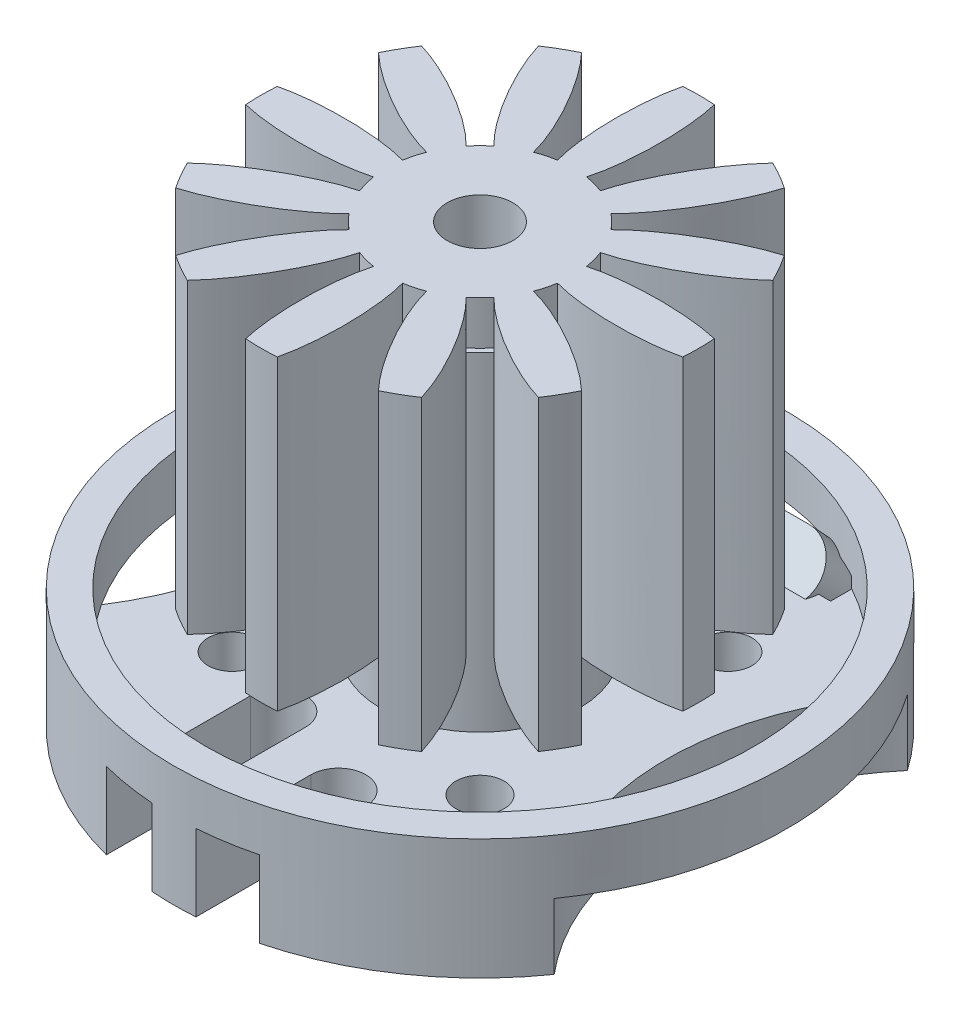
from build123d import *

# Parameters (mm, degrees)
SKETCH1_R                 = 14
BASE_DEPTH                = 5.5
SKETCH2_R                 = 12.5
BASECUT_DEPTH             = 2.5
SKETCH5_R                 = 4.5
OUTERSHAFT_DEPTH          = 15
SKETCH6_R                 = 12.5
LIGHTWEIGHT1_DEPTH        = 3
INDUCTORS_DEPTH           = 14
SKETCH7_W                 = 12
SKETCH7_H                 = 8
LIGHWEIGTH2_DEPTH         = 3.5
SKETCH8_R                 = 3.75
LIGHTWEIGHTFORSHAFT_DEPTH = 0.5
SKETCH9_R                 = 1.5
HOLEFORSHAFT_DEPTH        = 20.5000001
F_2_0_SCREWHOLES_D        = 2.2
F_2_0_SCREWHOLES_DEPTH    = 4
F_2_0_SCREWHOLES_TIP      = 0.660946681
CABLEOUT_DEPTH            = 5
CABLEOUT_TAPER            = 2
SKETCH13_R                = 1
BOSS_EXTRUDE2_DEPTH       = 2


with BuildPart() as part:
    # Sketch1 → Base (new body)
    with BuildSketch(Plane(origin=(0, 0, 0), x_dir=(1, 0, 0), z_dir=(0, 1, 0))):
        Circle(SKETCH1_R)
    extrude(amount=BASE_DEPTH)

    # Sketch2 → BaseCut (cut)
    with BuildSketch(Plane(origin=(0, 5.5, 0), x_dir=(1, 0, 0), z_dir=(0, 1, 0))):
        Circle(SKETCH2_R)
    extrude(amount=-BASECUT_DEPTH, mode=Mode.SUBTRACT)

    # Sketch5 → OuterShaft (add)
    with BuildSketch(Plane(origin=(0, 3, 0), x_dir=(1, 0, 0), z_dir=(0, 1, 0))):
        Circle(SKETCH5_R)
    extrude(amount=OUTERSHAFT_DEPTH)

    # Sketch6 → LightWeight1 (cut)
    with BuildSketch(Plane(origin=(0, 0, 0), x_dir=(-1, 0, 0), z_dir=(0, -1, 0))):
        with Locations((-21, 0)):
            Circle(SKETCH6_R)
        with Locations((21, 0)):
            Circle(SKETCH6_R)
    extrude(amount=-LIGHTWEIGHT1_DEPTH, mode=Mode.SUBTRACT)

    # Sketch4 → Inductors (add)
    with BuildSketch(Plane(origin=(0, 6, 0), x_dir=(1, 0, 0), z_dir=(0, 1, 0))):
        with BuildLine():
            ThreePointArc((-2.671623645, 3.305287748), (-3.00520382, 3.00520382), (-3.305287748, 2.671623645))
            add(Edge.make_bspline(
                [(-3.305287748, 2.671623645), (-5.30672078, 4.732784268), (-8.277571772, 5.610864957)],
                knots=[0.722217358, 0.722217358, 0.722217358, 2.33726322, 2.33726322, 2.33726322], degree=2, weights=[1, 0.691290425, 1]))
            ThreePointArc((-8.277571772, 5.610864957), (-8.660254038, 5), (-8.997937476, 4.363154957))
            add(Edge.make_bspline(
                [(-8.997937476, 4.363154957), (-6.752071797, 2.229362872), (-3.96633782, 1.526651334)],
                knots=[3.945922087, 3.945922087, 3.945922087, 5.560967949, 5.560967949, 5.560967949], degree=2, weights=[1, 0.691290425, 1]))
            ThreePointArc((-3.96633782, 1.526651334), (-4.105184762, 1.099980942), (-4.198274979, 0.661050072))
            add(Edge.make_bspline(
                [(-4.198274979, 0.661050072), (-6.96214714, 1.445351017), (-9.974019914, 0.720365704)],
                knots=[3.863810012, 3.863810012, 3.863810012, 5.478855873, 5.478855873, 5.478855873], degree=2, weights=[1, 0.691290425, 1]))
            ThreePointArc((-9.974019914, 0.720365704), (-10, 0), (-9.974019914, -0.720365704))
            add(Edge.make_bspline(
                [(-9.974019914, -0.720365704), (-6.96214714, -1.445351017), (-4.198274979, -0.661050072)],
                knots=[0.804329434, 0.804329434, 0.804329434, 2.419375295, 2.419375295, 2.419375295], degree=2, weights=[1, 0.691290425, 1]))
            ThreePointArc((-4.198274979, -0.661050072), (-4.105184762, -1.099980942), (-3.96633782, -1.526651334))
            add(Edge.make_bspline(
                [(-3.96633782, -1.526651334), (-6.752071797, -2.229362872), (-8.997937476, -4.363154957)],
                knots=[3.863810012, 3.863810012, 3.863810012, 5.478855873, 5.478855873, 5.478855873], degree=2, weights=[1, 0.691290425, 1]))
            ThreePointArc((-8.997937476, -4.363154957), (-8.660254038, -5), (-8.277571772, -5.610864957))
            add(Edge.make_bspline(
                [(-8.277571772, -5.610864957), (-5.30672078, -4.732784268), (-3.305287748, -2.671623645)],
                knots=[3.945922087, 3.945922087, 3.945922087, 5.560967949, 5.560967949, 5.560967949], degree=2, weights=[1, 0.691290425, 1]))
            ThreePointArc((-3.305287748, -2.671623645), (-3.00520382, -3.00520382), (-2.671623645, -3.305287748))
            add(Edge.make_bspline(
                [(-2.671623645, -3.305287748), (-4.732784268, -5.30672078), (-5.610864957, -8.277571772)],
                knots=[3.863810012, 3.863810012, 3.863810012, 5.478855873, 5.478855873, 5.478855873], degree=2, weights=[1, 0.691290425, 1]))
            ThreePointArc((-5.610864957, -8.277571772), (-5, -8.660254038), (-4.363154957, -8.997937476))
            add(Edge.make_bspline(
                [(-4.363154957, -8.997937476), (-2.229362872, -6.752071797), (-1.526651334, -3.96633782)],
                knots=[0.804329434, 0.804329434, 0.804329434, 2.419375295, 2.419375295, 2.419375295], degree=2, weights=[1, 0.691290425, 1]))
            ThreePointArc((-1.526651334, -3.96633782), (-1.099980942, -4.105184762), (-0.661050072, -4.198274979))
            add(Edge.make_bspline(
                [(-0.661050072, -4.198274979), (-1.445351017, -6.96214714), (-0.720365704, -9.974019914)],
                knots=[3.863810012, 3.863810012, 3.863810012, 5.478855873, 5.478855873, 5.478855873], degree=2, weights=[1, 0.691290425, 1]))
            ThreePointArc((-0.720365704, -9.974019914), (0, -10), (0.720365704, -9.974019914))
            add(Edge.make_bspline(
                [(0.720365704, -9.974019914), (1.445351017, -6.96214714), (0.661050072, -4.198274979)],
                knots=[0.804329434, 0.804329434, 0.804329434, 2.419375295, 2.419375295, 2.419375295], degree=2, weights=[1, 0.691290425, 1]))
            ThreePointArc((0.661050072, -4.198274979), (1.099980942, -4.105184762), (1.526651334, -3.96633782))
            add(Edge.make_bspline(
                [(1.526651334, -3.96633782), (2.229362872, -6.752071797), (4.363154957, -8.997937476)],
                knots=[0.722217358, 0.722217358, 0.722217358, 2.33726322, 2.33726322, 2.33726322], degree=2, weights=[1, 0.691290425, 1]))
            ThreePointArc((4.363154957, -8.997937476), (5, -8.660254038), (5.610864957, -8.277571772))
            add(Edge.make_bspline(
                [(5.610864957, -8.277571772), (4.732784268, -5.30672078), (2.671623645, -3.305287748)],
                knots=[0.804329434, 0.804329434, 0.804329434, 2.419375295, 2.419375295, 2.419375295], degree=2, weights=[1, 0.691290425, 1]))
            ThreePointArc((2.671623645, -3.305287748), (3.00520382, -3.00520382), (3.305287748, -2.671623645))
            add(Edge.make_bspline(
                [(3.305287748, -2.671623645), (5.30672078, -4.732784268), (8.277571772, -5.610864957)],
                knots=[3.863810012, 3.863810012, 3.863810012, 5.478855873, 5.478855873, 5.478855873], degree=2, weights=[1, 0.691290425, 1]))
            ThreePointArc((8.277571772, -5.610864957), (8.660254038, -5), (8.997937476, -4.363154957))
            add(Edge.make_bspline(
                [(8.997937476, -4.363154957), (6.752071797, -2.229362872), (3.96633782, -1.526651334)],
                knots=[0.804329434, 0.804329434, 0.804329434, 2.419375295, 2.419375295, 2.419375295], degree=2, weights=[1, 0.691290425, 1]))
            ThreePointArc((3.96633782, -1.526651334), (4.105184762, -1.099980942), (4.198274979, -0.661050072))
            add(Edge.make_bspline(
                [(4.198274979, -0.661050072), (6.96214714, -1.445351017), (9.974019914, -0.720365704)],
                knots=[3.863810012, 3.863810012, 3.863810012, 5.478855873, 5.478855873, 5.478855873], degree=2, weights=[1, 0.691290425, 1]))
            ThreePointArc((9.974019914, -0.720365704), (10, 0), (9.974019914, 0.720365704))
            add(Edge.make_bspline(
                [(9.974019914, 0.720365704), (6.96214714, 1.445351017), (4.198274979, 0.661050072)],
                knots=[0.804329434, 0.804329434, 0.804329434, 2.419375295, 2.419375295, 2.419375295], degree=2, weights=[1, 0.691290425, 1]))
            ThreePointArc((4.198274979, 0.661050072), (4.105184762, 1.099980942), (3.96633782, 1.526651334))
            add(Edge.make_bspline(
                [(3.96633782, 1.526651334), (6.752071797, 2.229362872), (8.997937476, 4.363154957)],
                knots=[3.863810012, 3.863810012, 3.863810012, 5.478855873, 5.478855873, 5.478855873], degree=2, weights=[1, 0.691290425, 1]))
            ThreePointArc((8.997937476, 4.363154957), (8.660254038, 5), (8.277571772, 5.610864957))
            add(Edge.make_bspline(
                [(8.277571772, 5.610864957), (5.30672078, 4.732784268), (3.305287748, 2.671623645)],
                knots=[3.945922087, 3.945922087, 3.945922087, 5.560967949, 5.560967949, 5.560967949], degree=2, weights=[1, 0.691290425, 1]))
            ThreePointArc((3.305287748, 2.671623645), (3.00520382, 3.00520382), (2.671623645, 3.305287748))
            add(Edge.make_bspline(
                [(2.671623645, 3.305287748), (4.732784268, 5.30672078), (5.610864957, 8.277571772)],
                knots=[3.863810012, 3.863810012, 3.863810012, 5.478855873, 5.478855873, 5.478855873], degree=2, weights=[1, 0.691290425, 1]))
            ThreePointArc((5.610864957, 8.277571772), (5, 8.660254038), (4.363154957, 8.997937476))
            add(Edge.make_bspline(
                [(4.363154957, 8.997937476), (2.229362872, 6.752071797), (1.526651334, 3.96633782)],
                knots=[0.804329434, 0.804329434, 0.804329434, 2.419375295, 2.419375295, 2.419375295], degree=2, weights=[1, 0.691290425, 1]))
            ThreePointArc((1.526651334, 3.96633782), (1.099980942, 4.105184762), (0.661050072, 4.198274979))
            add(Edge.make_bspline(
                [(0.661050072, 4.198274979), (1.445351017, 6.96214714), (0.720365704, 9.974019914)],
                knots=[0.722217358, 0.722217358, 0.722217358, 2.33726322, 2.33726322, 2.33726322], degree=2, weights=[1, 0.691290425, 1]))
            ThreePointArc((0.720365704, 9.974019914), (0, 10), (-0.720365704, 9.974019914))
            add(Edge.make_bspline(
                [(-0.720365704, 9.974019914), (-1.445351017, 6.96214714), (-0.661050072, 4.198274979)],
                knots=[0.804329434, 0.804329434, 0.804329434, 2.419375295, 2.419375295, 2.419375295], degree=2, weights=[1, 0.691290425, 1]))
            ThreePointArc((-0.661050072, 4.198274979), (-1.099980942, 4.105184762), (-1.526651334, 3.96633782))
            add(Edge.make_bspline(
                [(-1.526651334, 3.96633782), (-2.229362872, 6.752071797), (-4.363154957, 8.997937476)],
                knots=[3.863810012, 3.863810012, 3.863810012, 5.478855873, 5.478855873, 5.478855873], degree=2, weights=[1, 0.691290425, 1]))
            ThreePointArc((-4.363154957, 8.997937476), (-5, 8.660254038), (-5.610864957, 8.277571772))
            add(Edge.make_bspline(
                [(-5.610864957, 8.277571772), (-4.732784268, 5.30672078), (-2.671623645, 3.305287748)],
                knots=[0.804329434, 0.804329434, 0.804329434, 2.419375295, 2.419375295, 2.419375295], degree=2, weights=[1, 0.691290425, 1]))
        make_face()
    extrude(amount=INDUCTORS_DEPTH)

    # Sketch7 → LighWeigth2 (cut)
    with BuildSketch(Plane.XZ):
        with BuildLine():
            Line((-3.5, 13.964240044), (-3.5, 6.964240044))
            ThreePointArc((-3.5, 6.964240044), (-2.25, 5.714240044), (-1, 6.964240044))
            Line((-1, 6.964240044), (-1, 13.964240044))
            Line((-1, 13.964240044), (-3.5, 13.964240044))
        make_face()
        with Locations((0, -14)):
            Rectangle(SKETCH7_W, SKETCH7_H)
        with BuildLine():
            Line((1, 13.964240044), (1, 8.714240044))
            ThreePointArc((1, 8.714240044), (2.25, 7.464240044), (3.5, 8.714240044))
            Line((3.5, 8.714240044), (3.5, 13.964240044))
            Line((3.5, 13.964240044), (1, 13.964240044))
        make_face()
    extrude(amount=-LIGHWEIGTH2_DEPTH, mode=Mode.SUBTRACT)

    # Sketch8 → LightWeightForShaft (cut)
    with BuildSketch(Plane(origin=(0, 0, 0), x_dir=(-1, 0, 0), z_dir=(0, -1, 0))):
        Circle(SKETCH8_R)
    extrude(amount=-LIGHTWEIGHTFORSHAFT_DEPTH, mode=Mode.SUBTRACT)

    # Sketch9 → HoleForShaft (cut, through all)
    with BuildSketch(Plane(origin=(0, 0.5, 0), x_dir=(-1, 0, 0), z_dir=(0, -1, 0))):
        Circle(SKETCH9_R)
    extrude(amount=-HOLEFORSHAFT_DEPTH, mode=Mode.SUBTRACT)

    # Ø2.0 ScrewHoles
    with Locations(Plane(origin=(0, 0, 0), x_dir=(-1, 0, 0), z_dir=(0, -1, 0))):
        with Locations((-5.656854249, 5.656854249), (5.656854249, 5.656854249), (5.656854249, -5.656854249), (-5.656854249, -5.656854249)):
            Hole(F_2_0_SCREWHOLES_D / 2, depth=F_2_0_SCREWHOLES_DEPTH)
            with Locations((0, 0, -(F_2_0_SCREWHOLES_DEPTH + F_2_0_SCREWHOLES_TIP / 2))):  # 118° drill point
                Cone(0, F_2_0_SCREWHOLES_D / 2, F_2_0_SCREWHOLES_TIP, mode=Mode.SUBTRACT)

    # Sketch12 → cableOut (add)
    with BuildSketch(Plane(origin=(0, -3.25, -3.25), x_dir=(-1, 0, 0), z_dir=(0, -0.707106781, -0.707106781))):
        with BuildLine():
            ThreePointArc((-4, 10.992388155), (-5.5, 9.492388155), (-4, 7.992388155))
            Line((-4, 7.992388155), (4, 7.992388155))
            ThreePointArc((4, 7.992388155), (5.5, 9.492388155), (4, 10.992388155))
            Line((4, 10.992388155), (-4, 10.992388155))
        make_face()
    extrude(amount=CABLEOUT_DEPTH, taper=CABLEOUT_TAPER)

    # Sketch13 → Boss-Extrude2 (add)
    with BuildSketch(Plane(origin=(0, -6.785533906, -6.785533906), x_dir=(-1, 0, 0), z_dir=(0, -0.707106781, -0.707106781))):
        with Locations((-2.1, 9.492388155)):
            Circle(SKETCH13_R)
        with Locations((0, 9.492388155)):
            Circle(SKETCH13_R)
        with Locations((2.1, 9.492388155)):
            Circle(SKETCH13_R)
    extrude(amount=BOSS_EXTRUDE2_DEPTH)


solid = part.part
